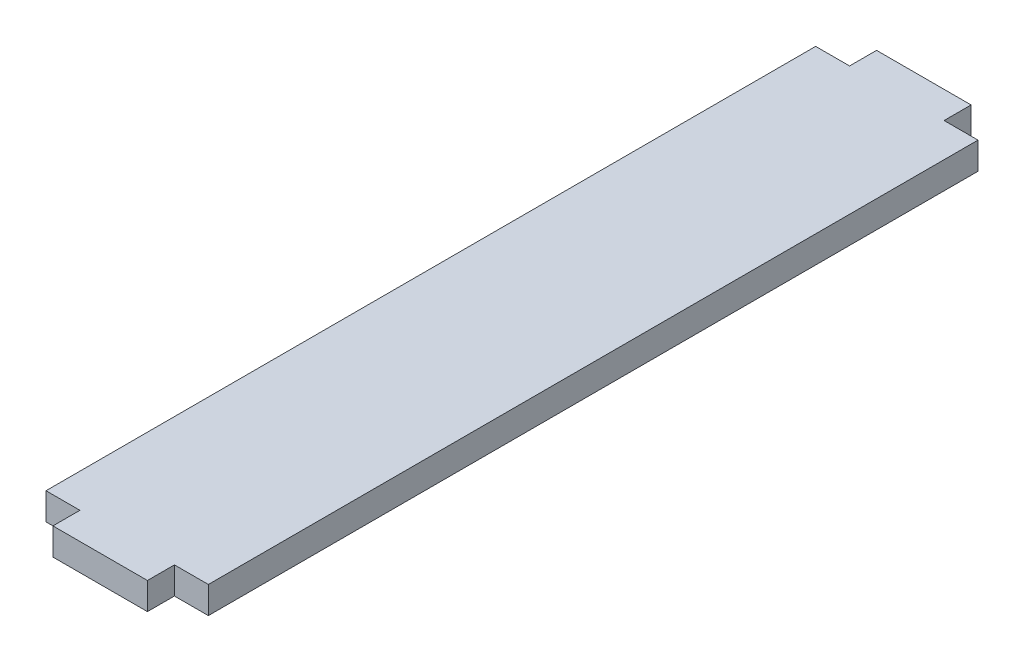
from build123d import *

# Parameters (mm, degrees)
SKETCH1_W           = 30.54
SKETCH1_H           = 144.78
BOSS_EXTRUDE1_DEPTH = 5.08
SKETCH2_W           = 17.78
SKETCH2_H           = 5.08
BOSS_EXTRUDE2_DEPTH = 5.08
SKETCH3_W           = 17.78
SKETCH3_H           = 5.08
BOSS_EXTRUDE3_DEPTH = 5.08


with BuildPart() as part:
    # Sketch1 → Boss-Extrude1 (new body)
    with BuildSketch(Plane(origin=(0, 0, 0), x_dir=(1, 0, 0), z_dir=(0, 1, 0))):
        with Locations((-15.27, 72.39)):
            Rectangle(SKETCH1_W, SKETCH1_H)
    extrude(amount=BOSS_EXTRUDE1_DEPTH)

    # Sketch2 → Boss-Extrude2 (add)
    with BuildSketch(Plane.XY):
        with Locations((-15.27, 2.54)):
            Rectangle(SKETCH2_W, SKETCH2_H)
    extrude(amount=BOSS_EXTRUDE2_DEPTH)

    # Sketch3 → Boss-Extrude3 (add)
    with BuildSketch(Plane(origin=(0, 0, -144.78), x_dir=(-1, 0, 0), z_dir=(0, 0, -1))):
        with Locations((15.27, 2.54)):
            Rectangle(SKETCH3_W, SKETCH3_H)
    extrude(amount=BOSS_EXTRUDE3_DEPTH)


solid = part.part
